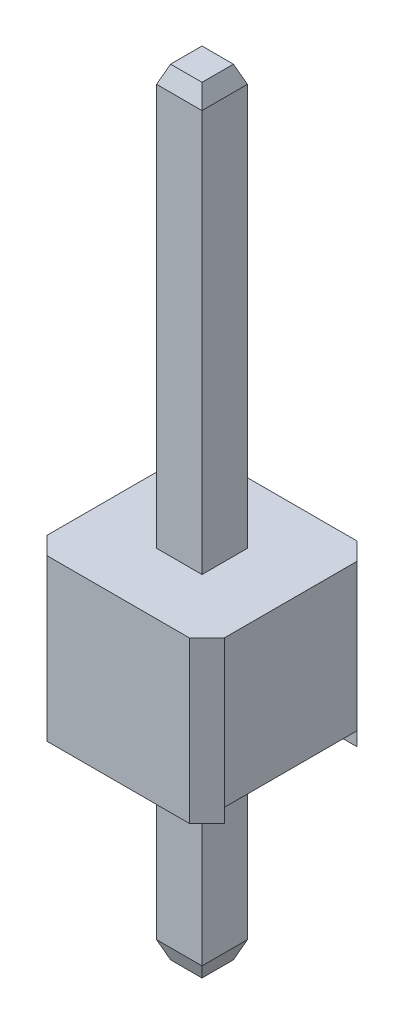
from build123d import *
from OCP.BRepFilletAPI import BRepFilletAPI_MakeChamfer

# Parameters (mm, degrees)
SKETCH1_W           = 0.65
SKETCH1_H           = 0.65
BOSS_EXTRUDE1_DEPTH = 11.3
CHAMFER1_SIZE       = 0.25
CHAMFER1_SIZE2      = 0.1
CHAMFER2_SIZE       = 0.1
CHAMFER2_SIZE2      = 0.25
SKETCH2_W           = 2.54
SKETCH2_H           = 2.4
BOSS_EXTRUDE2_DEPTH = 2.3
CHAMFER3_SIZE       = 0.25
SKETCH6_W           = 1.9
SKETCH6_H           = 0.2
CUT_EXTRUDE5_DEPTH  = 6
SKETCH7_W           = 0.65
SKETCH7_H           = 0.65
BOSS_EXTRUDE4_DEPTH = 3
CHAMFER5_SIZE       = 0.25
CHAMFER5_SIZE2      = 0.1


with BuildPart() as part:
    # Sketch1 → Boss-Extrude1 (new body)
    with BuildSketch(Plane(origin=(0, 0, 0), x_dir=(1, 0, 0), z_dir=(0, 1, 0))):
        with Locations((0.325, -0.325)):
            Rectangle(SKETCH1_W, SKETCH1_H)
    extrude(amount=BOSS_EXTRUDE1_DEPTH)

    # Chamfer1: one chamfer whose edges measure the first distance from different faces: ONE call of the kernel's chamfer builder (chamfer() names one face for all edges)
    chamfer1_edges_1 = [part.edges().sort_by_distance(p)[0] for p in [
        (0.65, 11.3, 0.325),
    ]]
    chamfer1_side_1 = [part.faces().sort_by_distance(p)[0] for p in [
        (0.65, 5.65, 0.325),
    ]]
    chamfer1_edges_2 = [part.edges().sort_by_distance(p)[0] for p in [
        (0.325, 11.3, 0),
    ]]
    chamfer1_side_2 = [part.faces().sort_by_distance(p)[0] for p in [
        (0.325, 5.65, 0),
    ]]
    chamfer1_edges_3 = [part.edges().sort_by_distance(p)[0] for p in [
        (0, 11.3, 0.325),
    ]]
    chamfer1_side_3 = [part.faces().sort_by_distance(p)[0] for p in [
        (0, 5.65, 0.325),
    ]]
    chamfer1_edges_4 = [part.edges().sort_by_distance(p)[0] for p in [
        (0.325, 11.3, 0.65),
    ]]
    chamfer1_side_4 = [part.faces().sort_by_distance(p)[0] for p in [
        (0.325, 5.65, 0.65),
    ]]
    chamfer1 = BRepFilletAPI_MakeChamfer(part.part.solid().wrapped)
    for e in chamfer1_edges_1:
        chamfer1.Add(CHAMFER1_SIZE, CHAMFER1_SIZE2, e.wrapped, chamfer1_side_1[0].wrapped)  # the first distance lies on this face
    for e in chamfer1_edges_2:
        chamfer1.Add(CHAMFER1_SIZE, CHAMFER1_SIZE2, e.wrapped, chamfer1_side_2[0].wrapped)  # the first distance lies on this face
    for e in chamfer1_edges_3:
        chamfer1.Add(CHAMFER1_SIZE, CHAMFER1_SIZE2, e.wrapped, chamfer1_side_3[0].wrapped)  # the first distance lies on this face
    for e in chamfer1_edges_4:
        chamfer1.Add(CHAMFER1_SIZE, CHAMFER1_SIZE2, e.wrapped, chamfer1_side_4[0].wrapped)  # the first distance lies on this face
    add(Compound.cast(chamfer1.Shape()), mode=Mode.REPLACE)

    # Chamfer2
    chamfer2_edges = [part.edges().sort_by_distance(p)[0] for p in [
        (0.325, 0, 0),
        (0.65, 0, 0.325),
        (0.325, 0, 0.65),
        (0, 0, 0.325),
    ]]
    chamfer2_side = [part.faces().sort_by_distance(p)[0] for p in [
        (0.325, 0, 0.325),
    ]]
    chamfer(chamfer2_edges, length=CHAMFER2_SIZE, length2=CHAMFER2_SIZE2, reference=chamfer2_side[0])

    # Sketch2 → Boss-Extrude2 (add)
    with BuildSketch(Plane(origin=(0, 3, 0), x_dir=(-1, 0, 0), z_dir=(0, -1, 0))):
        with Locations((-0.325, -0.325)):
            Rectangle(SKETCH2_W, SKETCH2_H)
    extrude(amount=-BOSS_EXTRUDE2_DEPTH)

    # Chamfer3
    chamfer3_edges = [part.edges().sort_by_distance(p)[0] for p in [
        (1.595, 4.15, 1.525),
        (1.595, 4.15, -0.875),
        (-0.945, 4.15, -0.875),
        (-0.945, 4.15, 1.525),
    ]]
    chamfer(chamfer3_edges, length=CHAMFER3_SIZE)

    # Sketch6 → Cut-Extrude5 (cut)
    with BuildSketch(Plane(origin=(1.595, 0, 0), x_dir=(0, 0, -1), z_dir=(1, 0, 0))):
        with Locations((-0.325, 3.1)):
            Rectangle(SKETCH6_W, SKETCH6_H)
    extrude(amount=-CUT_EXTRUDE5_DEPTH, mode=Mode.SUBTRACT)


with BuildPart() as body_2:
    # of the pieces the cut leaves, the one that is kept (cut_extrude5_keep)
    add(part.part.solids().sort_by_distance((1.345, 3, -0.875))[0])

    # Sketch7 → Boss-Extrude4 (add)
    with BuildSketch(Plane.XZ.offset(-3.2)):
        with Locations((0.325, 0.325)):
            Rectangle(SKETCH7_W, SKETCH7_H)
    extrude(amount=BOSS_EXTRUDE4_DEPTH)

    # Chamfer5: one chamfer whose edges measure the first distance from different faces: ONE call of the kernel's chamfer builder (chamfer() names one face for all edges)
    chamfer5_edges_1 = [body_2.edges().sort_by_distance(p)[0] for p in [
        (0, 0.2, 0.325),
    ]]
    chamfer5_side_1 = [body_2.faces().sort_by_distance(p)[0] for p in [
        (0, 1.7, 0.325),
    ]]
    chamfer5_edges_2 = [body_2.edges().sort_by_distance(p)[0] for p in [
        (0.325, 0.2, 0),
    ]]
    chamfer5_side_2 = [body_2.faces().sort_by_distance(p)[0] for p in [
        (0.325, 1.7, 0),
    ]]
    chamfer5_edges_3 = [body_2.edges().sort_by_distance(p)[0] for p in [
        (0.65, 0.2, 0.325),
    ]]
    chamfer5_side_3 = [body_2.faces().sort_by_distance(p)[0] for p in [
        (0.65, 1.7, 0.325),
    ]]
    chamfer5_edges_4 = [body_2.edges().sort_by_distance(p)[0] for p in [
        (0.325, 0.2, 0.65),
    ]]
    chamfer5_side_4 = [body_2.faces().sort_by_distance(p)[0] for p in [
        (0.325, 1.7, 0.65),
    ]]
    chamfer5 = BRepFilletAPI_MakeChamfer(body_2.part.solid().wrapped)
    for e in chamfer5_edges_1:
        chamfer5.Add(CHAMFER5_SIZE, CHAMFER5_SIZE2, e.wrapped, chamfer5_side_1[0].wrapped)  # the first distance lies on this face
    for e in chamfer5_edges_2:
        chamfer5.Add(CHAMFER5_SIZE, CHAMFER5_SIZE2, e.wrapped, chamfer5_side_2[0].wrapped)  # the first distance lies on this face
    for e in chamfer5_edges_3:
        chamfer5.Add(CHAMFER5_SIZE, CHAMFER5_SIZE2, e.wrapped, chamfer5_side_3[0].wrapped)  # the first distance lies on this face
    for e in chamfer5_edges_4:
        chamfer5.Add(CHAMFER5_SIZE, CHAMFER5_SIZE2, e.wrapped, chamfer5_side_4[0].wrapped)  # the first distance lies on this face
    add(Compound.cast(chamfer5.Shape()), mode=Mode.REPLACE)


solid = body_2.part
